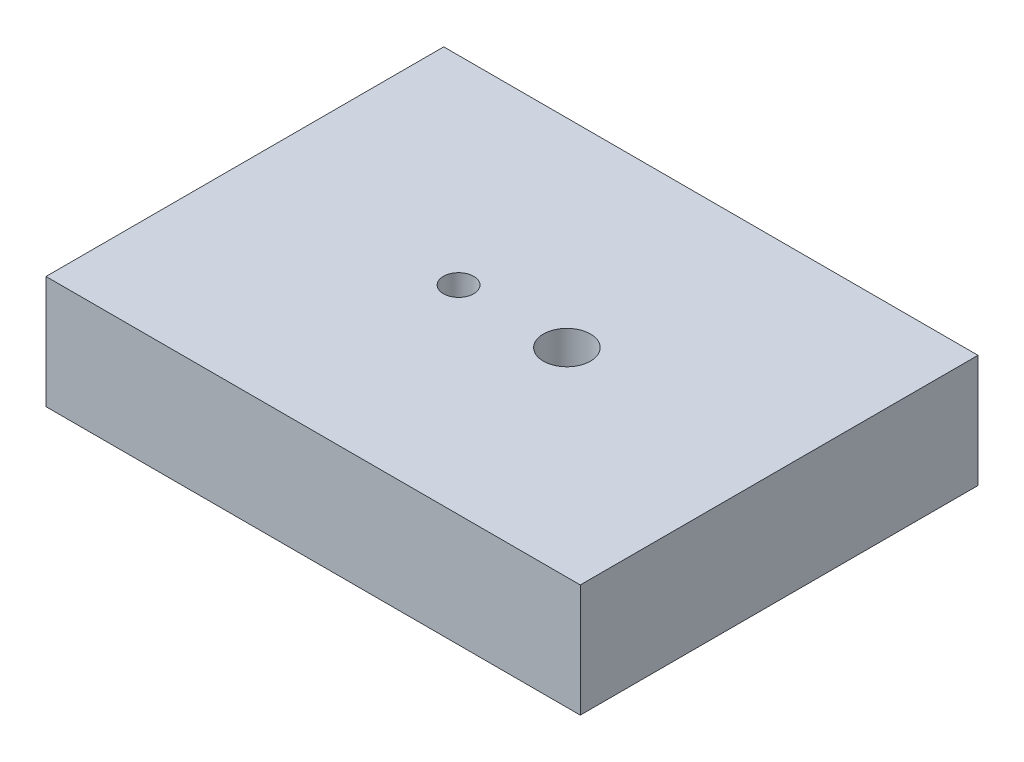
from build123d import *

# Parameters (mm, degrees)
SKETCH_1_W            = 90
SKETCH_1_H            = 67
EXTRUDE_1_DEPTH       = 19
HOLE_WIZARD_1_4_201_D = 5.1054
HOLE_WIZARD_3_8_161_D = 7.9375


with BuildPart() as part:
    # Эскиз1 → Бобышка-Вытянуть1 (new body)
    with BuildSketch(Plane(origin=(0, 0, 0), x_dir=(1, 0, 0), z_dir=(0, 1, 0))):
        with Locations((45, -33.5)):
            Rectangle(SKETCH_1_W, SKETCH_1_H)
    extrude(amount=EXTRUDE_1_DEPTH)

    # Отверстие обработанное метчиком 1/4-201 (through all)
    with Locations(Plane(origin=(36, 0, 33.5), x_dir=(0, 0, -1), z_dir=(0, -1, 0))):
        with Locations((0, 0)):
            Hole(HOLE_WIZARD_1_4_201_D / 2)

    # Отверстие обработанное метчиком 3/8-161 (through all)
    with Locations(Plane(origin=(54.25, 0, 33.5), x_dir=(0, 0, -1), z_dir=(0, -1, 0))):
        with Locations((0, 0)):
            Hole(HOLE_WIZARD_3_8_161_D / 2)


solid = part.part
